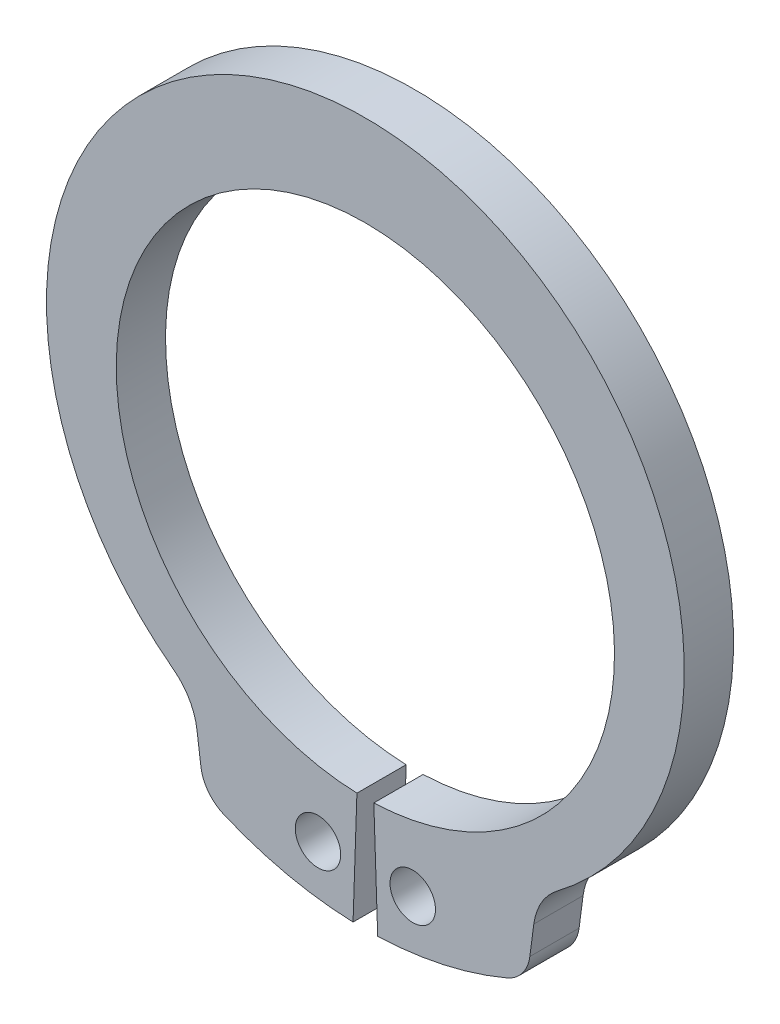
from build123d import *

# Parameters (mm, degrees)
BODYSKE_R  = 0.6
BODY_DEPTH = 1.3


with BuildPart() as part:
    # BodySke → Body (new body)
    with BuildSketch(Plane.XY):
        with BuildLine():
            Line((0.223172324, -6.571211389), (0.325, -9.569482745))
            ThreePointArc((0.325, -9.569482745), (2.067179303, -9.349192197), (3.739828154, -8.81443761))
            ThreePointArc((3.739828154, -8.81443761), (4.145198739, -8.499227928), (4.340690441, -8.024395905))
            Line((4.340690441, -8.024395905), (4.445467219, -7.228537259))
            ThreePointArc((4.445467219, -7.228537259), (4.649323286, -6.632069256), (5.06788143, -6.160751471))
            ThreePointArc((5.06788143, -6.160751471), (0, 8.975), (-5.06788143, -6.160751471))
            ThreePointArc((-5.06788143, -6.160751471), (-4.649323286, -6.632069256), (-4.445467219, -7.228537259))
            Line((-4.445467219, -7.228537259), (-4.340690441, -8.024395905))
            ThreePointArc((-4.340690441, -8.024395905), (-4.145198739, -8.499227928), (-3.739828154, -8.81443761))
            ThreePointArc((-3.739828154, -8.81443761), (-2.067179303, -9.349192197), (-0.325, -9.569482745))
            Line((-0.325, -9.569482745), (-0.223172324, -6.571211389))
            ThreePointArc((-0.223172324, -6.571211389), (0, 6.575), (0.223172324, -6.571211389))
        make_face()
        with Locations((1.25, -8.192689195)):
            Circle(BODYSKE_R, mode=Mode.SUBTRACT)
        with Locations((-1.25, -8.192689195)):
            Circle(BODYSKE_R, mode=Mode.SUBTRACT)
    extrude(amount=-BODY_DEPTH)


solid = part.part
